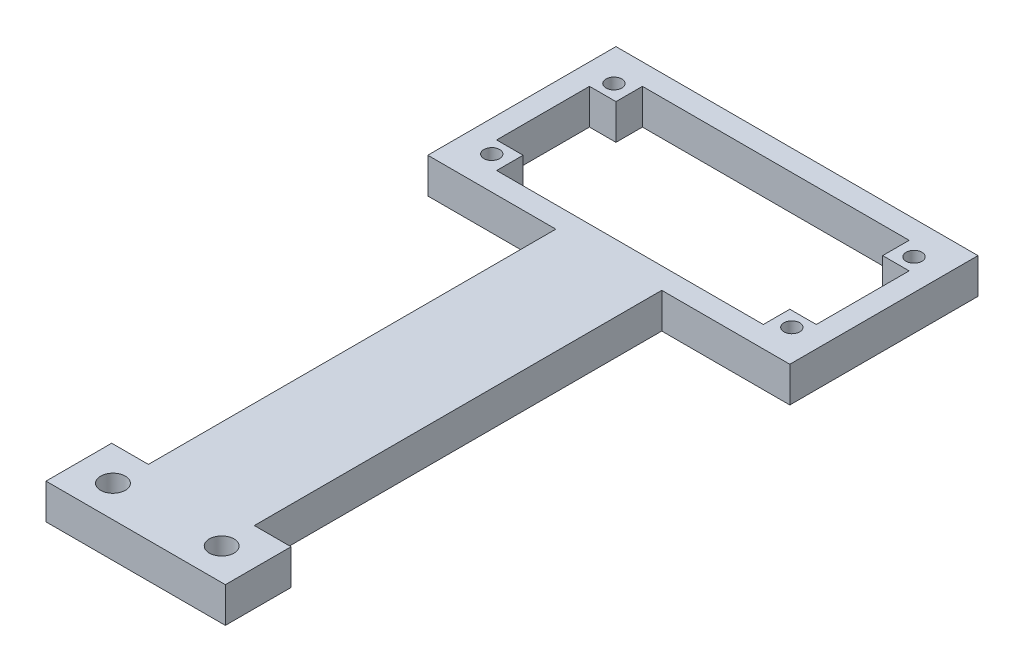
from build123d import *

# Parameters (mm, degrees)
SKETCH2_W           = 51.27
SKETCH2_H           = 26.65
BOSS_EXTRUDE2_DEPTH = 5
SKETCH3_W           = 45.27
SKETCH3_H           = 20.65
CUT_EXTRUDE1_DEPTH  = 6
SKETCH4_W           = 3.75
SKETCH4_H           = 3.75
BOSS_EXTRUDE3_DEPTH = 5
SKETCH5_R           = 1.12
CUT_EXTRUDE2_DEPTH  = 6
SKETCH6_W           = 15
SKETCH6_H           = 57.7
BOSS_EXTRUDE4_DEPTH = 5
SKETCH7_W           = 25.4
SKETCH7_H           = 9.5
BOSS_EXTRUDE5_DEPTH = 5
SKETCH11_R          = 1.75
CUT_EXTRUDE5_DEPTH  = 6
SKETCH12_W          = 25.4
SKETCH12_H          = 0.2
CUT_EXTRUDE6_DEPTH  = 6


with BuildPart() as part:
    # Sketch2 → Boss-Extrude2 (new body)
    with BuildSketch(Plane(origin=(0, 0, 0), x_dir=(1, 0, 0), z_dir=(0, 1, 0))):
        with Locations((22.635, 10.325)):
            Rectangle(SKETCH2_W, SKETCH2_H)
    extrude(amount=BOSS_EXTRUDE2_DEPTH)

    # Sketch3 → Cut-Extrude1 (cut, through all)
    with BuildSketch(Plane(origin=(0, 5, 0), x_dir=(1, 0, 0), z_dir=(0, 1, 0))):
        with Locations((22.635, 10.325)):
            Rectangle(SKETCH3_W, SKETCH3_H)
    extrude(amount=-CUT_EXTRUDE1_DEPTH, mode=Mode.SUBTRACT)

    # Sketch4 → Boss-Extrude3 (add)
    with BuildSketch(Plane(origin=(0, 5, 0), x_dir=(1, 0, 0), z_dir=(0, 1, 0))):
        with Locations((1.875, 18.775)):
            Rectangle(SKETCH4_W, SKETCH4_H)
        with Locations((1.875, 1.875)):
            Rectangle(SKETCH4_W, SKETCH4_H)
        with Locations((43.395, 1.875)):
            Rectangle(SKETCH4_W, SKETCH4_H)
        with Locations((43.395, 18.775)):
            Rectangle(SKETCH4_W, SKETCH4_H)
    extrude(amount=-BOSS_EXTRUDE3_DEPTH)

    # Sketch5 → Cut-Extrude2 (cut, through all)
    with BuildSketch(Plane(origin=(0, 5, 0), x_dir=(1, 0, 0), z_dir=(0, 1, 0))):
        with Locations((1.385, 18.975)):
            Circle(SKETCH5_R)
        with Locations((43.885, 18.975)):
            Circle(SKETCH5_R)
        with Locations((43.885, 1.675)):
            Circle(SKETCH5_R)
        with Locations((1.385, 1.675)):
            Circle(SKETCH5_R)
    extrude(amount=-CUT_EXTRUDE2_DEPTH, mode=Mode.SUBTRACT)

    # Sketch6 → Boss-Extrude4 (add)
    with BuildSketch(Plane(origin=(0, 5, 0), x_dir=(1, 0, 0), z_dir=(0, 1, 0))):
        with Locations((22.635, -31.85)):
            Rectangle(SKETCH6_W, SKETCH6_H)
    extrude(amount=-BOSS_EXTRUDE4_DEPTH)

    # Sketch7 → Boss-Extrude5 (add)
    with BuildSketch(Plane(origin=(0, 5, 0), x_dir=(1, 0, 0), z_dir=(0, 1, 0))):
        with Locations((22.635, -65.45)):
            Rectangle(SKETCH7_W, SKETCH7_H)
    extrude(amount=-BOSS_EXTRUDE5_DEPTH)

    # Sketch11 → Cut-Extrude5 (cut, through all)
    with BuildSketch(Plane.XZ):
        with Locations((30.335, 65.51777032)):
            Circle(SKETCH11_R)
        with Locations((14.935, 65.51777032)):
            Circle(SKETCH11_R)
    extrude(amount=-CUT_EXTRUDE5_DEPTH, mode=Mode.SUBTRACT)

    # Sketch12 → Cut-Extrude6 (cut, through all)
    with BuildSketch(Plane(origin=(0, 5, 0), x_dir=(1, 0, 0), z_dir=(0, 1, 0))):
        with Locations((22.635, -70.1)):
            Rectangle(SKETCH12_W, SKETCH12_H)
    extrude(amount=-CUT_EXTRUDE6_DEPTH, mode=Mode.SUBTRACT)


solid = part.part
